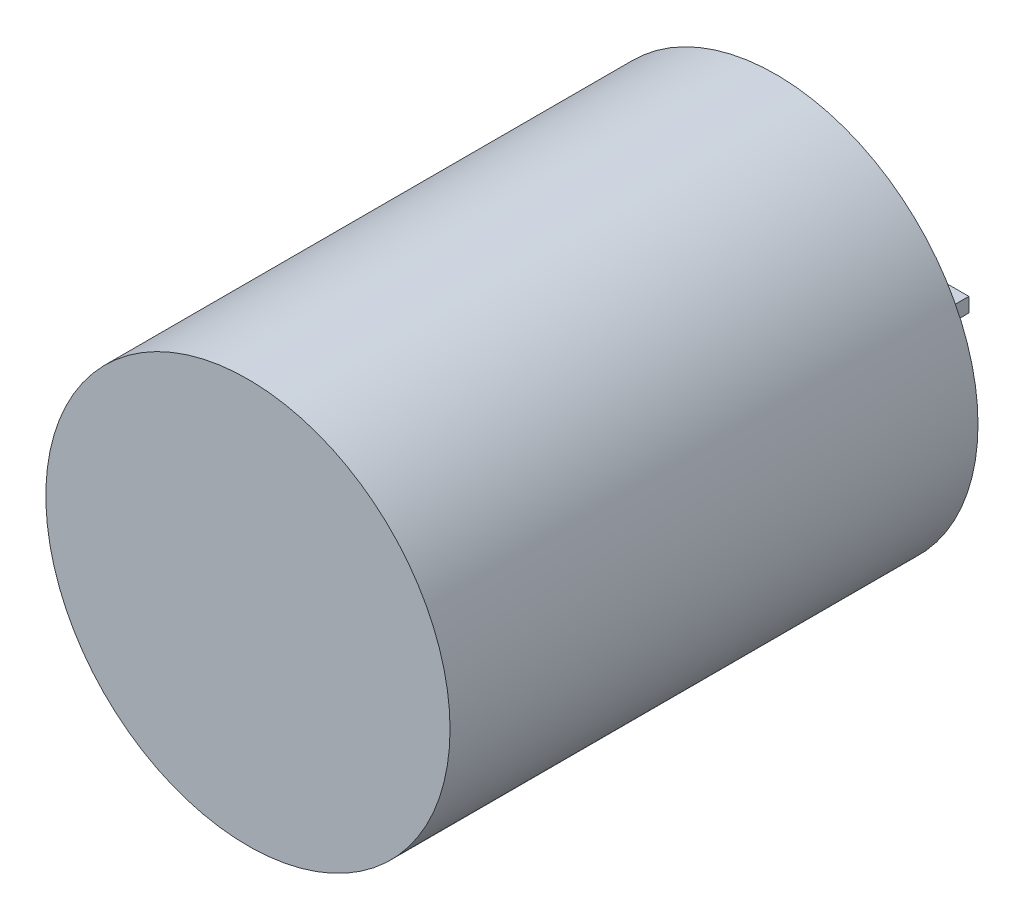
from build123d import *

# Parameters (mm, degrees)
SKETCH1_R           = 12.446
BOSS_EXTRUDE1_DEPTH = 32.512
SKETCH2_W           = 1.565145042
SKETCH2_H           = 0.889
BOSS_EXTRUDE2_DEPTH = 6.1


with BuildPart() as part:
    # Sketch1 → Boss-Extrude1 (new body)
    with BuildSketch(Plane.XY):
        Circle(SKETCH1_R)
    extrude(amount=BOSS_EXTRUDE1_DEPTH)

    # Sketch2 → Boss-Extrude2 (add)
    with BuildSketch(Plane.XY):
        with Locations((-5, 0)):
            Rectangle(SKETCH2_W, SKETCH2_H)
        with Locations((5, 0)):
            Rectangle(SKETCH2_W, SKETCH2_H)
    extrude(amount=-BOSS_EXTRUDE2_DEPTH)


solid = part.part
